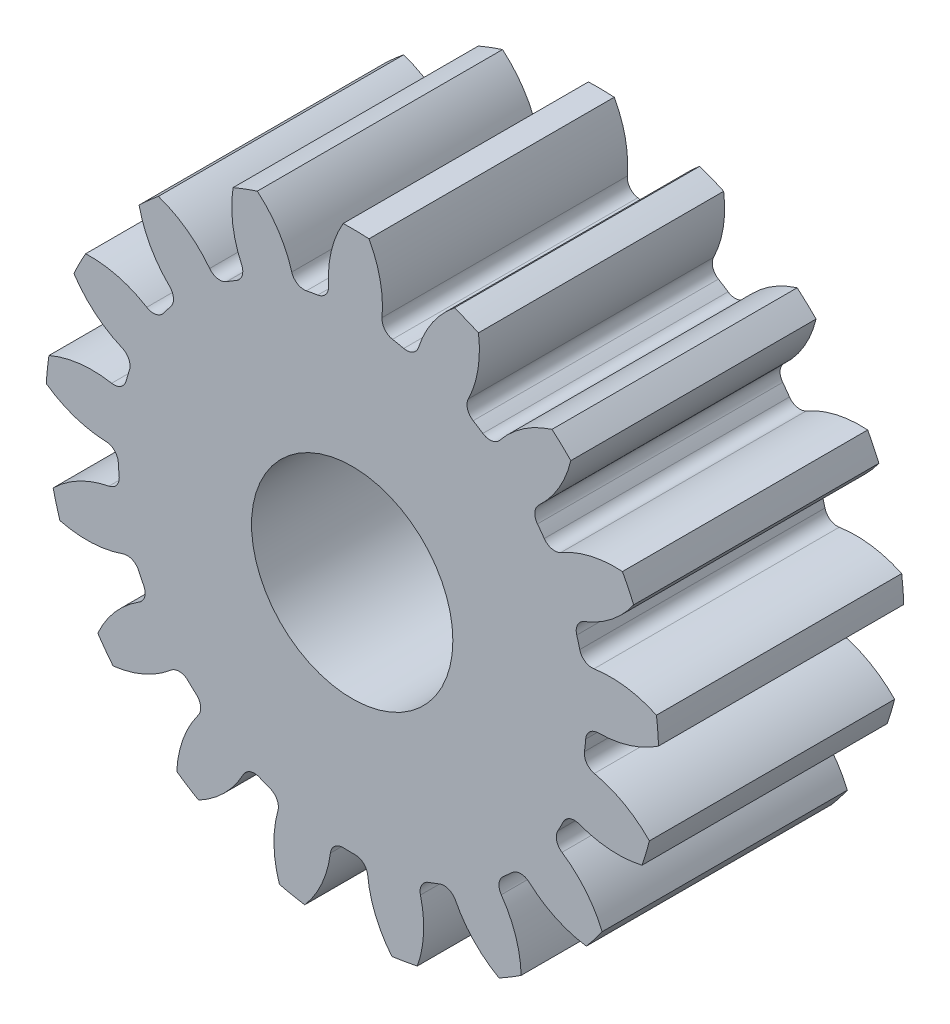
from build123d import *

# Parameters (mm, degrees)
SKETCH3_R         = 12.065
GEARBODY_DEPTH    = 9.652
TOOTHCUT_DEPTH    = 10.652
CIRPATTERN1_COUNT = 17
BOREDIA_R         = 3.9624
BORE_DEPTH        = 12700


with BuildPart() as part:
    # Sketch3 → gearBody (new body)
    with BuildSketch(Plane.XY):
        Circle(SKETCH3_R)
    extrude(amount=GEARBODY_DEPTH)

    # Sketch2 → toothCut (cut, through all)
    with BuildSketch(Plane.XY):
        with BuildLine():
            ThreePointArc((9.142823661, -1.191999807), (9.169284766, -0.967628503), (9.19024048, -0.742676218))
            ThreePointArc((9.19024048, -0.742676218), (9.348086694, -0.417154866), (9.684376414, -0.283780197))
            ThreePointArc((9.684376414, -0.283780197), (11.669443263, 0.21905505), (13.194238308, 1.585925107))
            ThreePointArc((13.194238308, 1.585925107), (13.215824396, -1.39465713), (12.572564615, -4.305078625))
            ThreePointArc((12.572564615, -4.305078625), (11.366669508, -2.650040659), (9.530287729, -1.743930488))
            ThreePointArc((9.530287729, -1.743930488), (9.229245497, -1.543298603), (9.142823661, -1.191999807))
        make_face()
    toothcut = extrude(amount=TOOTHCUT_DEPTH, mode=Mode.SUBTRACT)

    # CirPattern1: toothCut ×17 about axis
    cirpattern1_axis = Axis((0, 0, 0), (0, 0, 1))
    for i in range(1, CIRPATTERN1_COUNT):
        add(toothcut.rotate(cirpattern1_axis, i * 360 / CIRPATTERN1_COUNT), mode=Mode.SUBTRACT)

    # boreDia → bore (cut, symmetric)
    with BuildSketch(Plane.XY):
        Circle(BOREDIA_R)
    extrude(amount=BORE_DEPTH, both=True, mode=Mode.SUBTRACT)


solid = part.part
